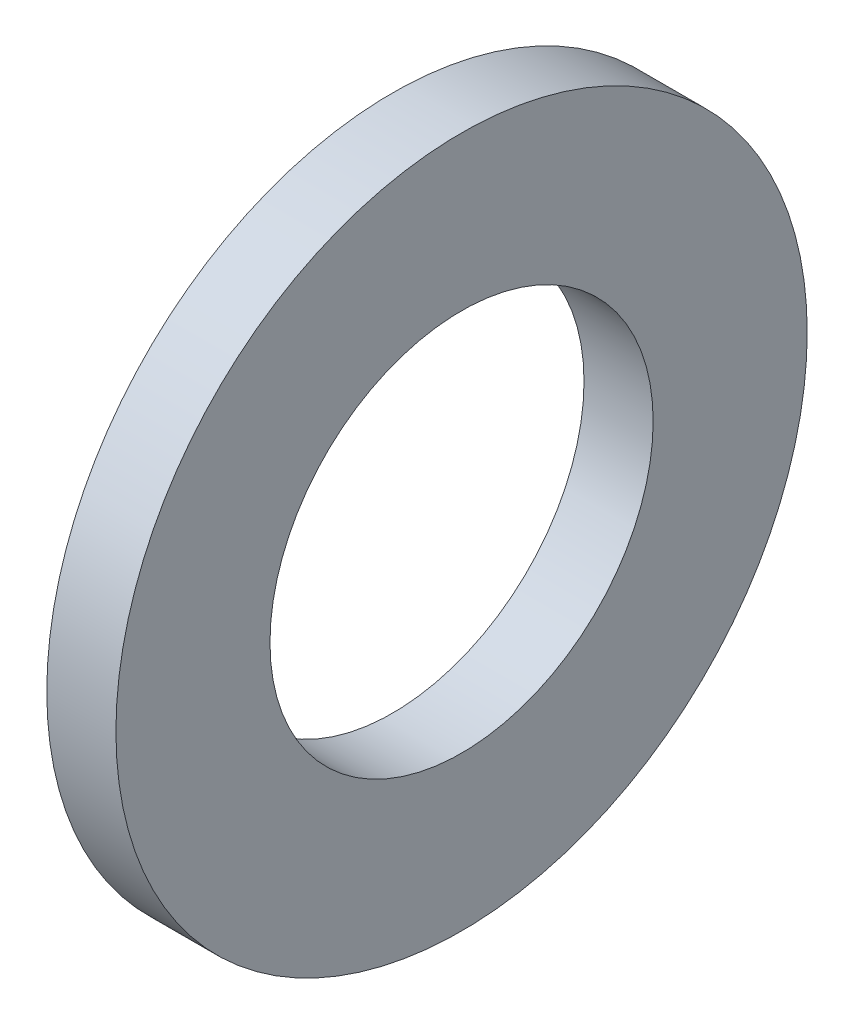
from build123d import *

# Parameters (mm, degrees)
SKETCH1_W = 2.8
SKETCH1_H = 6.24


with BuildPart() as part:
    # Sketch1 → Base-Revolve (revolve)
    with BuildSketch(Plane.XY):
        with Locations((-1.4, 10.88)):
            Rectangle(SKETCH1_W, SKETCH1_H)
    revolve(axis=Axis((-34.925, 0, 0), (1, 0, 0)))


solid = part.part
